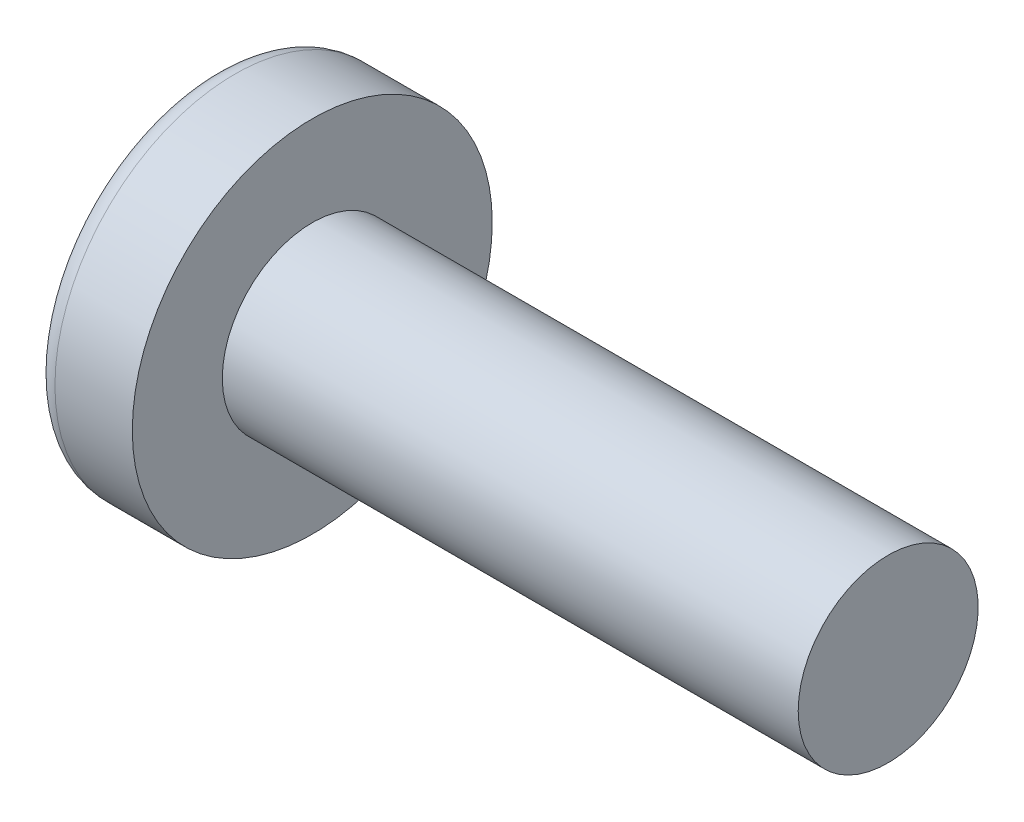
from build123d import *

# Parameters (mm, degrees)
SKETCH3_W         = 0.7
SKETCH3_H         = 2.68
SKETCH4_W         = 0.35
SKETCH4_H         = 0.35
CIRPATTERN1_COUNT = 2
CIRPATTERN1_ANGLE = 90


with BuildPart() as part:
    # BodySke → Base-Revolve (revolve)
    with BuildSketch(Plane.XY):
        with BuildLine():
            Line((2.1, 1.25), (2.1, 2.5))
            Line((2.1, 2.5), (1.025105044, 2.5))
            ThreePointArc((1.025105044, 2.5), (0.890037493, 2.467874517), (0.783897345, 2.378378378))
            ThreePointArc((0.783897345, 2.378378378), (0.201025755, 1.252116085), (0, 0))
            Line((0, 0), (10.1, 0))
            Line((10.1, 0), (10.1, 1.25))
            Line((10.1, 1.25), (2.1, 1.25))
        make_face()
    revolve(axis=Axis((-25.4, 0, 0), (1, 0, 0)))

    # Sketch3 → Cut-Loft1 section 0
    with BuildSketch(Plane(origin=(0, 0, 0), x_dir=(0, 0, -1), z_dir=(1, 0, 0))):
        Rectangle(SKETCH3_W, SKETCH3_H)
    # Sketch4 → Cut-Loft1 section 1
    with BuildSketch(Plane(origin=(1.53, 0, 0), x_dir=(0, 0, -1), z_dir=(1, 0, 0))):
        Rectangle(SKETCH4_W, SKETCH4_H)
    cut_loft1 = loft(mode=Mode.SUBTRACT)

    # CirPattern1: Cut-Loft1 ×2 about axis
    cirpattern1_axis = Axis((0, 0, 0), (1, 0, 0))
    for i in range(1, CIRPATTERN1_COUNT):
        add(cut_loft1.rotate(cirpattern1_axis, i * CIRPATTERN1_ANGLE / (CIRPATTERN1_COUNT - 1)), mode=Mode.SUBTRACT)


solid = part.part
